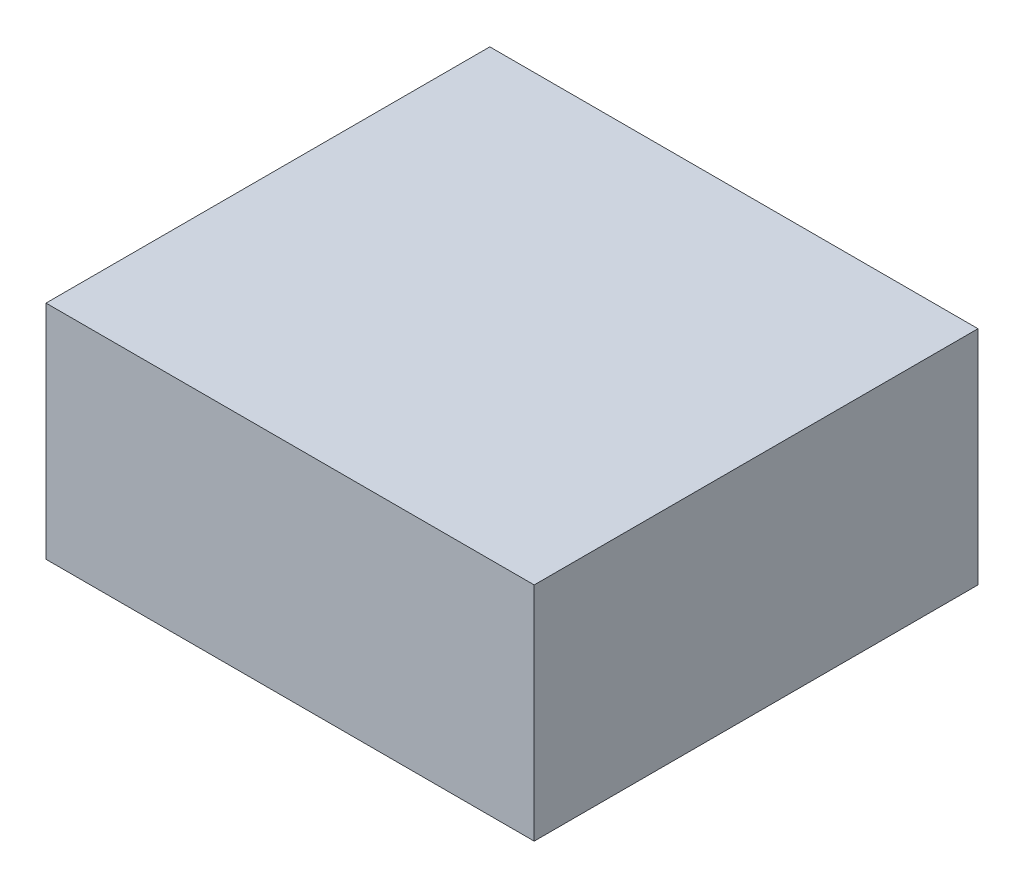
from build123d import *

# Parameters (mm, degrees)
ESQUISSE1_W        = 110
ESQUISSE1_H        = 50
BOSS_EXTRU_1_DEPTH = 100


with BuildPart() as part:
    # Esquisse1 → Boss.-Extru.1 (new body)
    with BuildSketch(Plane.XY):
        Rectangle(ESQUISSE1_W, ESQUISSE1_H)
    extrude(amount=BOSS_EXTRU_1_DEPTH)


solid = part.part
